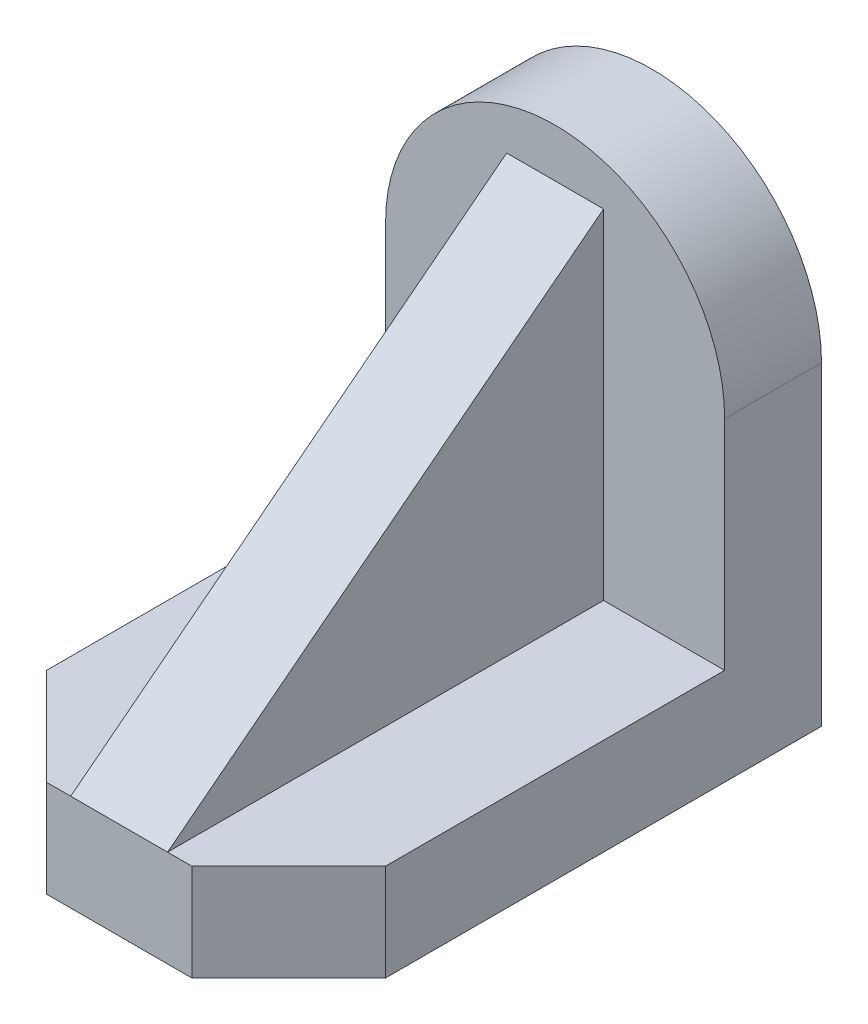
from build123d import *

# Parameters (mm, degrees)
SKETCH2_W           = 42
SKETCH2_H           = 66
BOSS_EXTRUDE1_DEPTH = 12
CHAMFER1_SIZE       = 12
SKETCH5_W           = 42
SKETCH5_H           = 12
BOSS_EXTRUDE2_DEPTH = 27
SKETCH6_W           = 21
SKETCH6_H           = 12
REVOLVE1_ANGLE      = 180
BOSS_EXTRUDE3_DEPTH = 6


with BuildPart() as part:
    # Sketch2 → Boss-Extrude1 (new body)
    with BuildSketch(Plane(origin=(0, 0, 0), x_dir=(1, 0, 0), z_dir=(0, 1, 0))):
        Rectangle(SKETCH2_W, SKETCH2_H)
    extrude(amount=BOSS_EXTRUDE1_DEPTH)

    # Chamfer1
    chamfer1_edges = [part.edges().sort_by_distance(p)[0] for p in [
        (21, 6, 33),
        (-21, 6, 33),
    ]]
    chamfer(chamfer1_edges, length=CHAMFER1_SIZE)

    # Sketch5 → Boss-Extrude2 (add)
    with BuildSketch(Plane(origin=(0, 12, 0), x_dir=(1, 0, 0), z_dir=(0, 1, 0))):
        with Locations((0, 27)):
            Rectangle(SKETCH5_W, SKETCH5_H)
    extrude(amount=BOSS_EXTRUDE2_DEPTH)

    # Sketch6 → Revolve1 (revolve)
    with BuildSketch(Plane(origin=(0, 39, 0), x_dir=(1, 0, 0), z_dir=(0, 1, 0))):
        with Locations((10.5, 27)):
            Rectangle(SKETCH6_W, SKETCH6_H)
    revolve(axis=Axis((0, 39, -33), (0, 0, 1)), revolution_arc=REVOLVE1_ANGLE)

    # Sketch9 → Boss-Extrude3 (add, symmetric)
    with BuildSketch(Plane(origin=(0, 0, 0), x_dir=(0, 0, -1), z_dir=(1, 0, 0))):
        Polygon((21, 12), (21, 54), (-33, 12), align=None)
    extrude(amount=BOSS_EXTRUDE3_DEPTH, both=True)


solid = part.part
